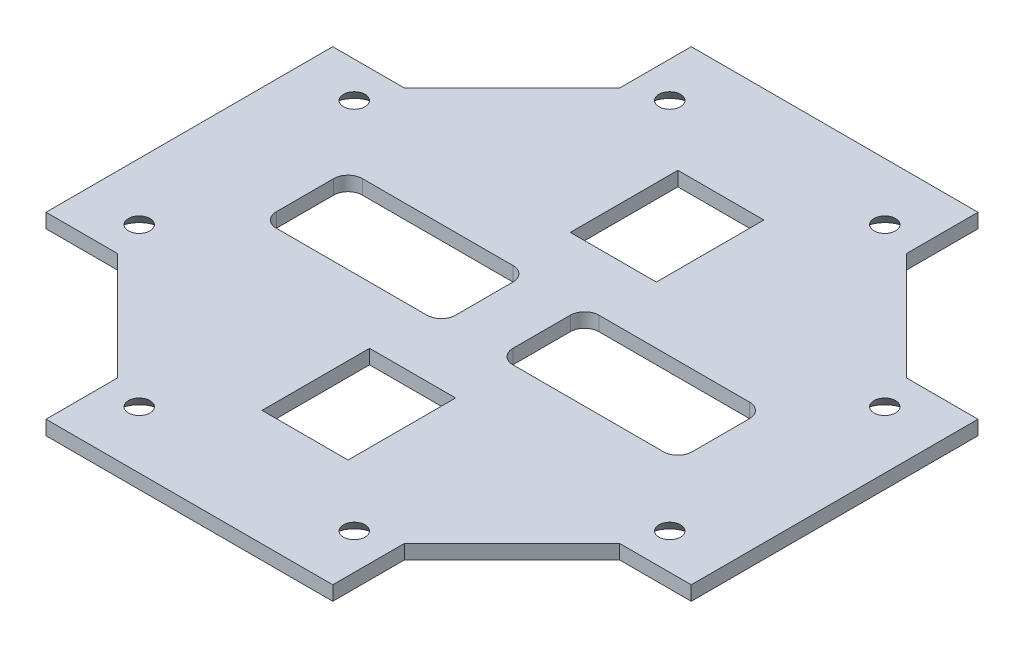
from build123d import *

# Parameters (mm, degrees)
RESSALTO_EXTRUS_O1_DEPTH        = 2
ESBO_O2_R                       = 1.5
CORTE_EXTRUS_O1_DEPTH           = 3
CORTE_EXTRUS_O1_TAPER           = -40
ESPELHAR3_COPY_1_SKETCH_R       = 1.5
ESPELHAR3_COPY_1_DEPTH          = 3
ESPELHAR3_COPY_1_TAPER          = -40
PADR_OCIRCULAR1_COUNT           = 2
PADR_OCIRCULAR1_ANGLE           = 90
PADR_OCIRCULAR1_COPY_1_SKETCH_R = 1.5
PADR_OCIRCULAR1_COPY_1_DEPTH    = 3
PADR_OCIRCULAR1_COPY_1_TAPER    = -40
PADR_OCIRCULAR1_COPY_2_SKETCH_R = 1.5
PADR_OCIRCULAR1_COPY_2_DEPTH    = 3
PADR_OCIRCULAR1_COPY_2_TAPER    = -40
PADR_OCIRCULAR1_COPY_3_SKETCH_R = 1.5
PADR_OCIRCULAR1_COPY_3_DEPTH    = 3
PADR_OCIRCULAR1_COPY_3_TAPER    = -40


with BuildPart() as part:
    # Esboço1 → Ressalto-extrusão1 (new body)
    with BuildSketch(Plane(origin=(0, 0, 0), x_dir=(1, 0, 0), z_dir=(0, 1, 0))):
        Polygon((-20, 35), (-20, 45), (0, 45), (0, 29.131440421), (-6, 29.131440421), (-6, 14.131440421), (0, 14.131440421), (0, -13.868559579), (-6, -13.868559579), (-6, -28.868559579), (0, -28.868559579), (0, -45), (-20, -45), (-20, -35), (-35, -20), (-45, -20), (-45, 20), (-35, 20), align=None)
        with BuildLine():
            Line((-27, -5.868559579), (-6, -5.868559579))
            ThreePointArc((-6, -5.868559579), (-4.585786438, -5.282773141), (-4, -3.868559579))
            Line((-4, -3.868559579), (-4, 4.131440421))
            ThreePointArc((-4, 4.131440421), (-4.585786438, 5.545653984), (-6, 6.131440421))
            Line((-6, 6.131440421), (-27, 6.131440421))
            ThreePointArc((-27, 6.131440421), (-28.414213562, 5.545653984), (-29, 4.131440421))
            Line((-29, 4.131440421), (-29, -3.868559579))
            ThreePointArc((-29, -3.868559579), (-28.414213562, -5.282773141), (-27, -5.868559579))
        make_face(mode=Mode.SUBTRACT)
    ressalto_extrus_o1 = extrude(amount=RESSALTO_EXTRUS_O1_DEPTH)

    # Espelhar1: Ressalto-extrusão1 across plane
    add(ressalto_extrus_o1.mirror(Plane(origin=(0, 0, 0), x_dir=(0, 0, 1), z_dir=(1, 0, 0))))

    # Esboço2 → Corte-extrusão1 (cut, through all)
    with BuildSketch(Plane(origin=(0, 2, 0), x_dir=(1, 0, 0), z_dir=(0, 1, 0))):
        with Locations((-15, 37)):
            Circle(ESBO_O2_R)
    corte_extrus_o1 = extrude(amount=-CORTE_EXTRUS_O1_DEPTH, taper=CORTE_EXTRUS_O1_TAPER, mode=Mode.SUBTRACT)

    # Espelhar2: Corte-extrusão1 across plane
    add(corte_extrus_o1.mirror(Plane(origin=(0, 0, 0), x_dir=(0, 0, 1), z_dir=(1, 0, 0))), mode=Mode.SUBTRACT)

    # Espelhar3: Corte-extrusão1 across plane
    add(corte_extrus_o1.mirror(Plane.XY), mode=Mode.SUBTRACT)

    # Espelhar3 copy 1 sketch → Espelhar3 copy 1 (cut, through all)
    with BuildSketch(Plane(origin=(0, 2, 0), x_dir=(-1, 0, 0), z_dir=(0, 1, 0))):
        with Locations((-15, 37)):
            Circle(ESPELHAR3_COPY_1_SKETCH_R)
    extrude(amount=-ESPELHAR3_COPY_1_DEPTH, taper=ESPELHAR3_COPY_1_TAPER, mode=Mode.SUBTRACT)

    # PadrãoCircular1: Corte-extrusão1 ×2 about axis
    padr_ocircular1_axis = Axis((0, 0, 0), (0, -1, 0))
    for i in range(1, PADR_OCIRCULAR1_COUNT):
        add(corte_extrus_o1.rotate(padr_ocircular1_axis, i * PADR_OCIRCULAR1_ANGLE / (PADR_OCIRCULAR1_COUNT - 1)), mode=Mode.SUBTRACT)

    # PadrãoCircular1 copy 1 sketch → PadrãoCircular1 copy 1 (cut, through all)
    with BuildSketch(Plane.ZX.offset(2)):
        with Locations((-15, -37)):
            Circle(PADR_OCIRCULAR1_COPY_1_SKETCH_R)
    extrude(amount=-PADR_OCIRCULAR1_COPY_1_DEPTH, taper=PADR_OCIRCULAR1_COPY_1_TAPER, mode=Mode.SUBTRACT)

    # PadrãoCircular1 copy 2 sketch → PadrãoCircular1 copy 2 (cut, through all)
    with BuildSketch(Plane(origin=(0, 2, 0), x_dir=(0, 0, -1), z_dir=(0, 1, 0))):
        with Locations((-15, 37)):
            Circle(PADR_OCIRCULAR1_COPY_2_SKETCH_R)
    extrude(amount=-PADR_OCIRCULAR1_COPY_2_DEPTH, taper=PADR_OCIRCULAR1_COPY_2_TAPER, mode=Mode.SUBTRACT)

    # PadrãoCircular1 copy 3 sketch → PadrãoCircular1 copy 3 (cut, through all)
    with BuildSketch(Plane(origin=(0, 2, 0), x_dir=(0, 0, -1), z_dir=(0, 1, 0))):
        with Locations((-15, -37)):
            Circle(PADR_OCIRCULAR1_COPY_3_SKETCH_R)
    extrude(amount=-PADR_OCIRCULAR1_COPY_3_DEPTH, taper=PADR_OCIRCULAR1_COPY_3_TAPER, mode=Mode.SUBTRACT)


solid = part.part
